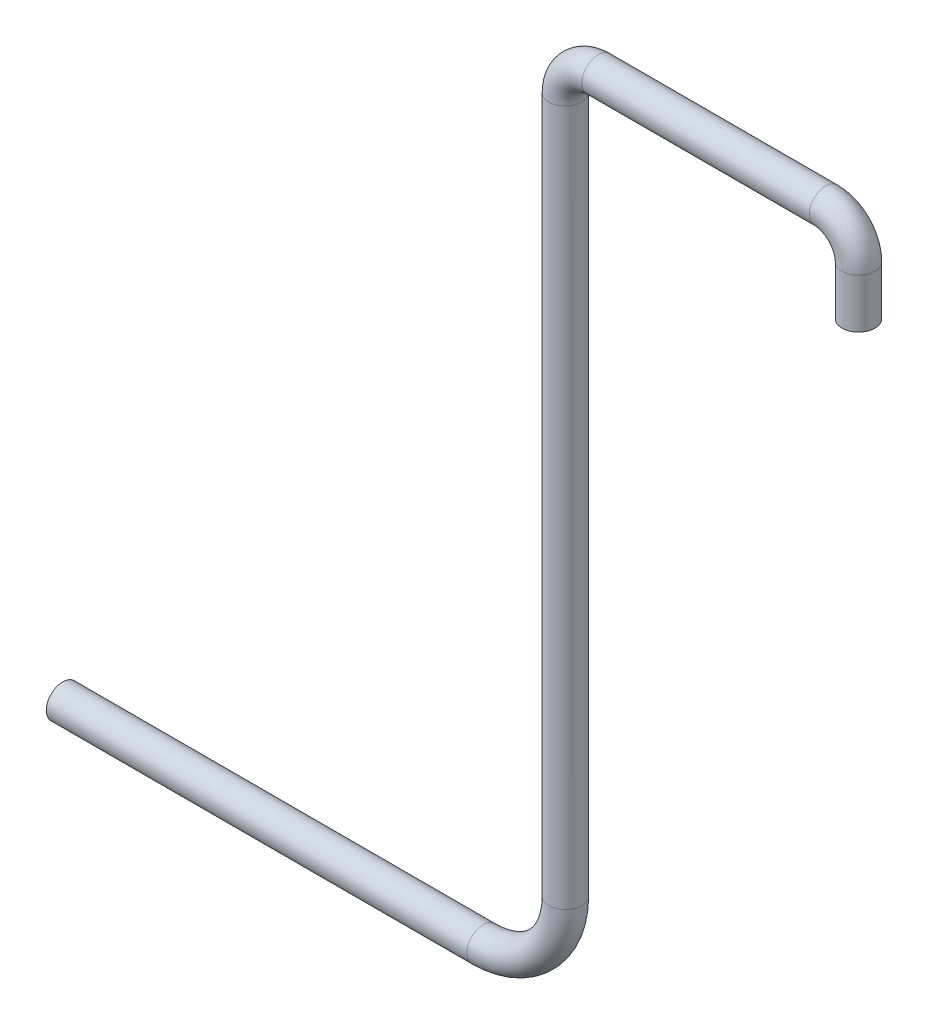
from build123d import *

# Parameters (mm, degrees)
ESQUISSE2_R = 0.1


with BuildPart() as part:
    # Balayage1: sweep along a path in Esquisse1
    with BuildLine(Plane.XY) as balayage1_path:
        Line((0, 0), (0, 0.3))
        ThreePointArc((0, 0.3), (-0.058578644, 0.441421356), (-0.2, 0.5))
        Line((-0.2, 0.5), (-1.584533741, 0.5))
        ThreePointArc((-1.584533741, 0.5), (-1.725955098, 0.441421356), (-1.784533741, 0.3))
        Line((-1.784533741, 0.3), (-1.784533741, -3.937120931))
        ThreePointArc((-1.784533741, -3.937120931), (-1.930980351, -4.290674321), (-2.284533741, -4.437120931))
        Line((-2.284533741, -4.437120931), (-4.845117945, -4.437120931))
    # Esquisse2 → Balayage1 (sweep)
    with BuildSketch(Plane(origin=(0, 0, 0), x_dir=(1, 0, 0), z_dir=(0, 1, 0))):
        Circle(ESQUISSE2_R)
    sweep(path=balayage1_path.line)


solid = part.part
